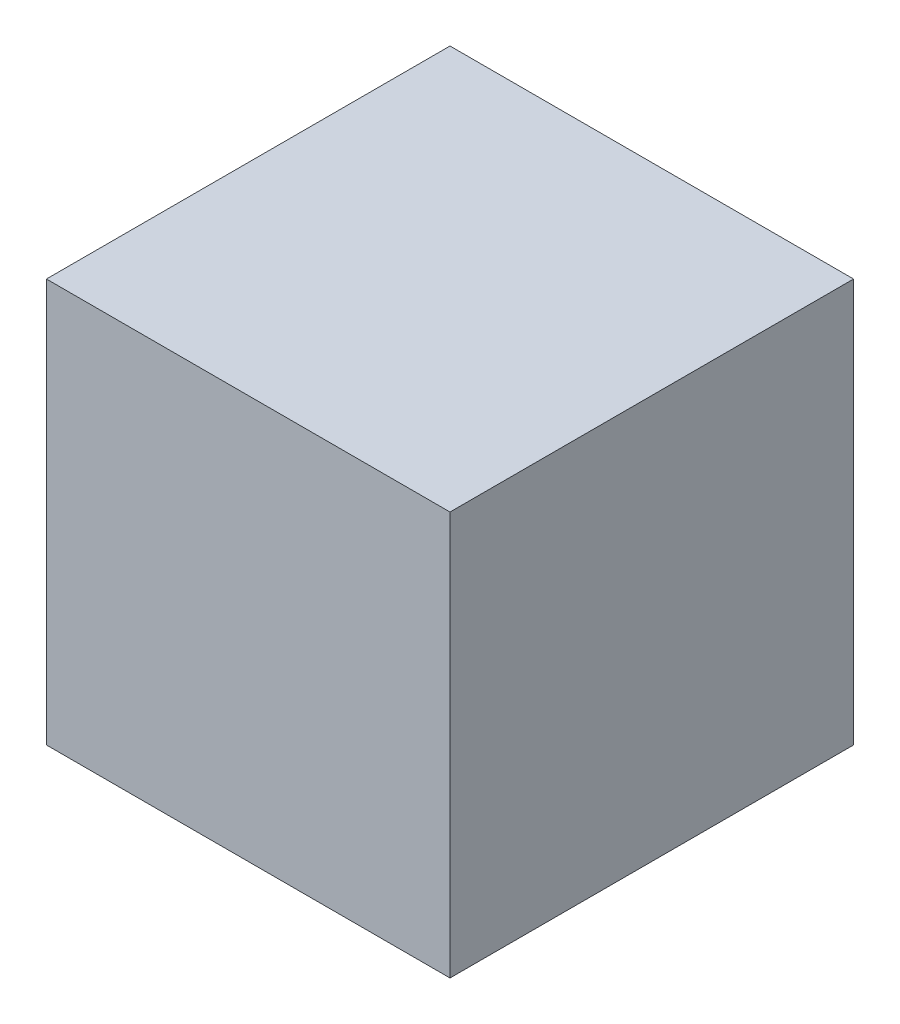
from build123d import *

# Parameters (mm, degrees)
SKETCH1_W           = 622.935
SKETCH1_H           = 622.935
BOSS_EXTRUDE1_DEPTH = 311.4675


with BuildPart() as part:
    # Sketch1 → Boss-Extrude1 (new body, symmetric)
    with BuildSketch(Plane(origin=(0, 0, 0), x_dir=(0, 0, -1), z_dir=(1, 0, 0))):
        Rectangle(SKETCH1_W, SKETCH1_H)
    extrude(amount=BOSS_EXTRUDE1_DEPTH, both=True)


solid = part.part
